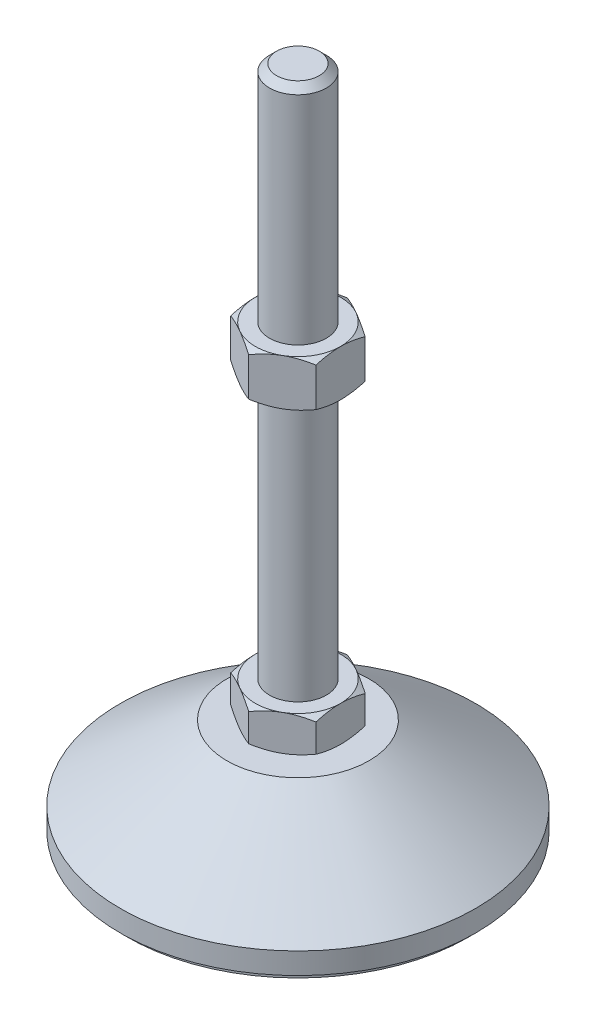
from build123d import *

# Parameters (mm, degrees)
EXTRUDE_1_DEPTH = 10
EXTRUDE_2_DEPTH = 13


with BuildPart() as part:
    # Эскиз1 → Повернуть1 (revolve)
    with BuildSketch(Plane.XY, mode=Mode.PRIVATE) as revolve_1_sk:
        Polygon((0, 0), (-48, 0), (-48, 2), (-50, 2), (-50, 8), (-20, 29), (-8, 29), (-8, 39), (-8, 187), (-6, 189), (0, 189), align=None)
    revolve(revolve_1_sk.sketch.rotate(Axis((0, 0, 0), (0, 1, 0)), 180), axis=Axis((0, 0, 0), (0, 1, 0)))  # turned: the seam where the file's is

    # Эскиз2 → Бобышка-Вытянуть1 (add)
    with BuildSketch(Plane(origin=(0, 29, 0), x_dir=(1, 0, 0), z_dir=(0, 1, 0))):
        Polygon((0, 13.856406461), (-12, 6.92820323), (-12, -6.92820323), (0, -13.856406461), (12, -6.92820323), (12, 6.92820323), align=None)
    extrude(amount=EXTRUDE_1_DEPTH)

    # Эскиз3 → Бобышка-Вытянуть2 (add)
    with BuildSketch(Plane(origin=(0, 113, 0), x_dir=(1, 0, 0), z_dir=(0, 1, 0))):
        Polygon((12, 6.92820323), (0, 13.856406461), (-12, 6.92820323), (-12, -6.92820323), (0, -13.856406461), (12, -6.92820323), align=None)
    extrude(amount=EXTRUDE_2_DEPTH)

    # Эскиз4 → Вырез-Повернуть2 (revolve, cut)
    with BuildSketch(Plane.XY, mode=Mode.PRIVATE) as cut_revolve_2_sk:
        Polygon((-23.258330249, 126), (-12, 126), (-23.258330249, 119.5), align=None)
        Polygon((-23.258330249, 113), (-23.258330249, 119.5), (-12, 113), align=None)
        Polygon((-20.660254038, 39), (-20.660254038, 34), (-12, 39), align=None)
        Polygon((-20.660254038, 34), (-20.660254038, 29), (-12, 29), align=None)
    revolve(cut_revolve_2_sk.sketch.rotate(Axis((0, 189, 0), (0, -1, 0)), 180), axis=Axis((0, 189, 0), (0, -1, 0)), mode=Mode.SUBTRACT)  # turned: the seam where the file's is


solid = part.part
